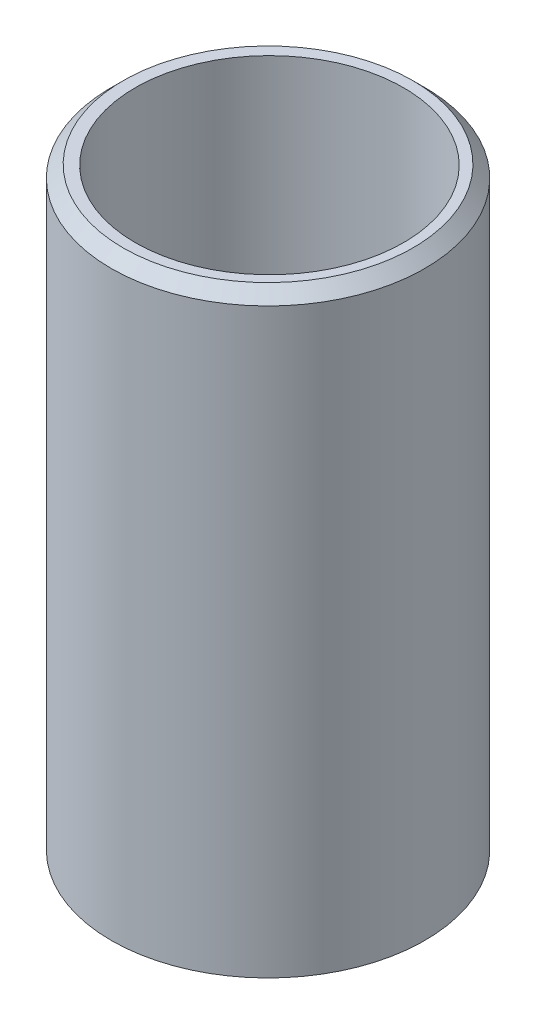
from build123d import *

# Parameters (mm, degrees)
SKETCH1_R           = 16.764
BOSS_EXTRUDE1_DEPTH = 63.5
SKETCH2_R           = 14.351
CUT_EXTRUDE1_DEPTH  = 166.37
CHAMFER1_SIZE       = 1.27


with BuildPart() as part:
    # Sketch1 → Boss-Extrude1 (new body)
    with BuildSketch(Plane(origin=(0, 0, 0), x_dir=(1, 0, 0), z_dir=(0, 1, 0))):
        with Locations((-13.41463778, 13.288084593)):
            Circle(SKETCH1_R)
    extrude(amount=BOSS_EXTRUDE1_DEPTH)

    # Sketch2 → Cut-Extrude1 (cut)
    with BuildSketch(Plane(origin=(0, 0, 0), x_dir=(1, 0, 0), z_dir=(0, 1, 0))):
        with Locations((-13.258576493, 13.278033005)):
            Circle(SKETCH2_R)
    extrude(amount=CUT_EXTRUDE1_DEPTH, mode=Mode.SUBTRACT)

    # Chamfer1
    chamfer1_edges = [part.edges().sort_by_distance(p)[0] for p in [
        (-30.17863778, 63.5, -13.288084593),
    ]]
    chamfer(chamfer1_edges, length=CHAMFER1_SIZE)


solid = part.part
